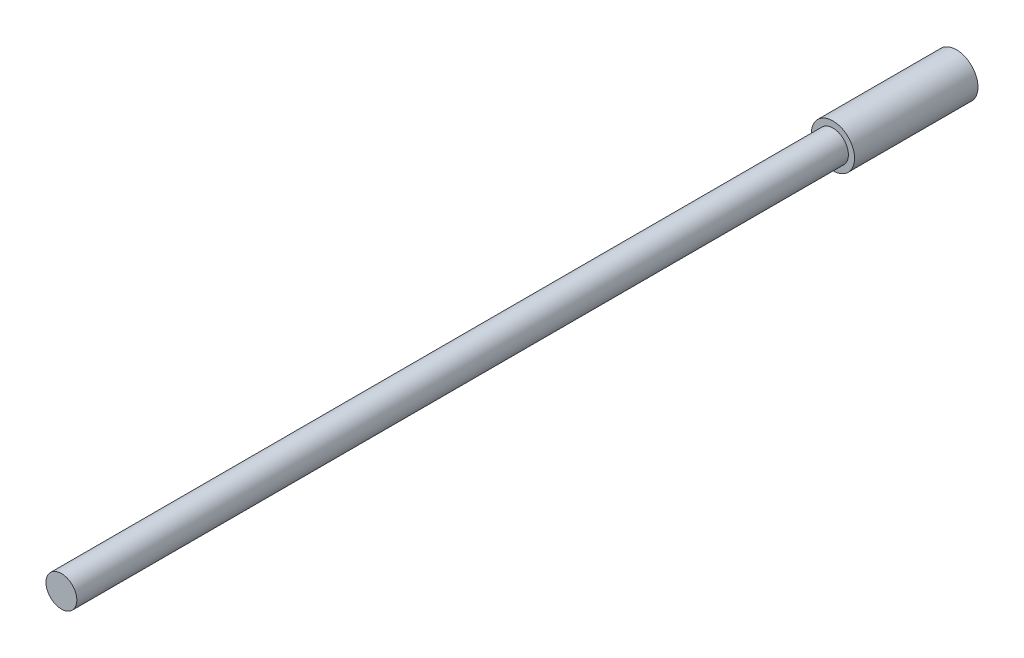
from build123d import *

# Parameters (mm, degrees)
SKETCH1_R           = 0.889
BOSS_EXTRUDE1_DEPTH = 5.08
SKETCH2_R           = 0.635
BOSS_EXTRUDE2_DEPTH = 31.75


with BuildPart() as part:
    # Sketch1 → Boss-Extrude1 (new body)
    with BuildSketch(Plane.XY):
        Circle(SKETCH1_R)
    extrude(amount=BOSS_EXTRUDE1_DEPTH)

    # Sketch2 → Boss-Extrude2 (add)
    with BuildSketch(Plane.XY.offset(5.08)):
        Circle(SKETCH2_R)
    extrude(amount=BOSS_EXTRUDE2_DEPTH)


solid = part.part
